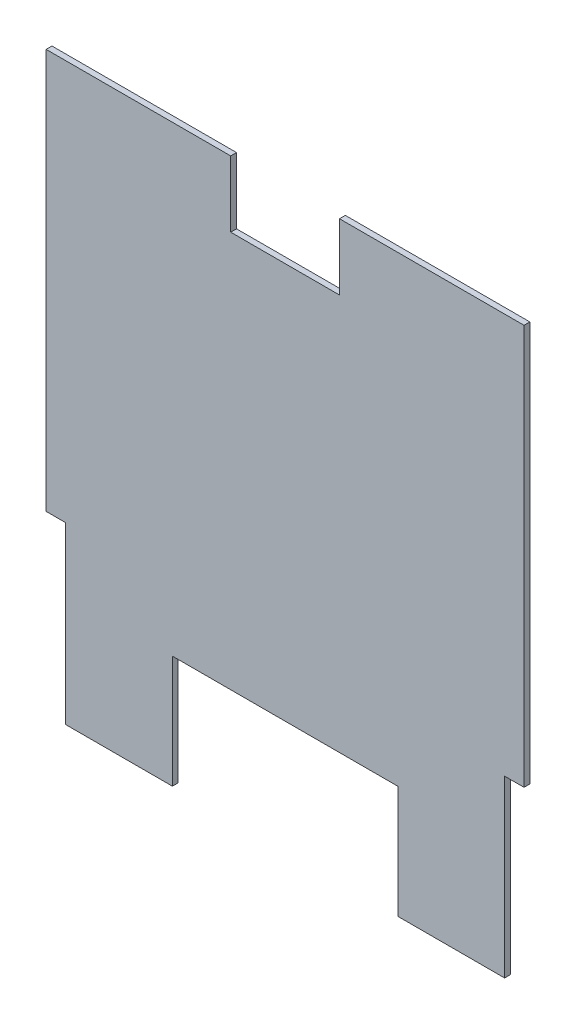
from build123d import *

# Parameters (mm, degrees)
BOSS_EXTRUDE1_DEPTH = 4.7625


with BuildPart() as part:
    # Sketch1 → Boss-Extrude1 (new body)
    with BuildSketch(Plane.XY):
        Polygon((-92.075, -234.95), (-179.3875, -234.95), (-179.3875, -92.075), (-195.2625, -92.075), (-195.2625, 234.95), (-44.45, 234.95), (-44.45, 180.975), (44.45, 180.975), (44.45, 234.95), (195.2625, 234.95), (195.2625, -92.075), (179.3875, -92.075), (179.3875, -234.95), (92.075, -234.95), (92.075, -142.875), (-92.075, -142.875), align=None)
    extrude(amount=BOSS_EXTRUDE1_DEPTH)


solid = part.part
